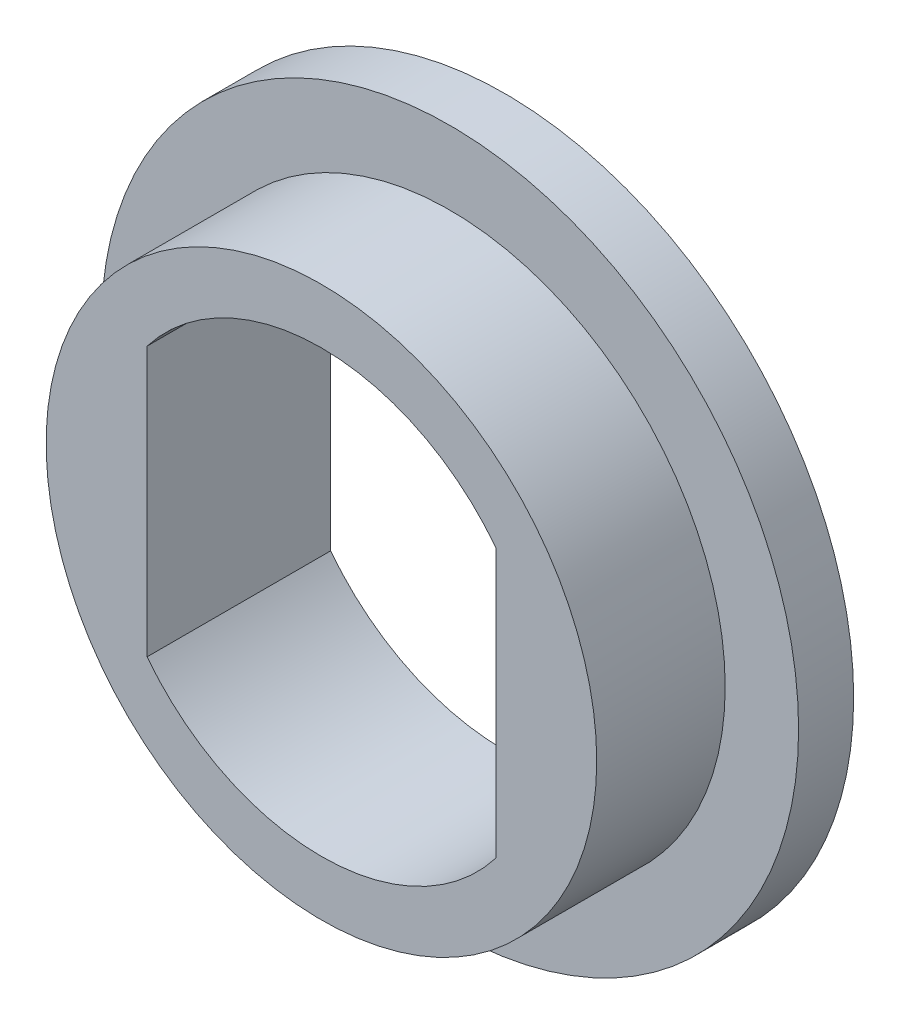
from build123d import *

# Parameters (mm, degrees)
ESQUISSE1_R        = 15
BOSS_EXTRU_1_DEPTH = 7
BOSS_EXTRU_2_START = -3
ESQUISSE1_4_R      = 19
BOSS_EXTRU_2_DEPTH = 3


with BuildPart() as part:
    # Esquisse1 → Boss.-Extru.1 (new body)
    with BuildSketch(Plane.XY):
        Circle(ESQUISSE1_R)
        with BuildLine():
            Line((9.5, 7.331439149), (9.5, -7.331439149))
            ThreePointArc((9.5, -7.331439149), (0, -12), (-9.5, -7.331439149))
            Line((-9.5, -7.331439149), (-9.5, 7.331439149))
            ThreePointArc((-9.5, 7.331439149), (0, 12), (9.5, 7.331439149))
        make_face(mode=Mode.SUBTRACT)
    extrude(amount=BOSS_EXTRU_1_DEPTH)

    # Esquisse1_4 → Boss.-Extru.2 (add)
    with BuildSketch(Plane.XY.offset(BOSS_EXTRU_2_START)):
        Circle(ESQUISSE1_4_R)
        with BuildLine():
            Line((9.5, 7.331439149), (9.5, -7.331439149))
            ThreePointArc((9.5, -7.331439149), (0, -12), (-9.5, -7.331439149))
            Line((-9.5, -7.331439149), (-9.5, 7.331439149))
            ThreePointArc((-9.5, 7.331439149), (0, 12), (9.5, 7.331439149))
        make_face(mode=Mode.SUBTRACT)
    extrude(amount=BOSS_EXTRU_2_DEPTH)


solid = part.part
